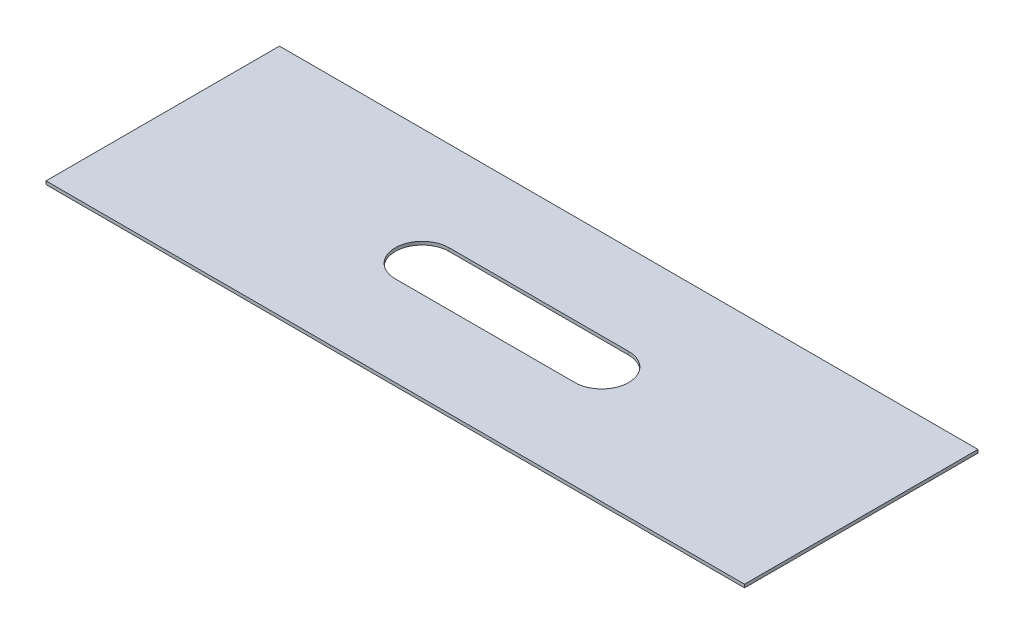
from build123d import *

# Parameters (mm, degrees)
SKETCH1_W           = 98.806
SKETCH1_H           = 33.02
BOSS_EXTRUDE1_DEPTH = 0.4572
CUT_EXTRUDE1_DEPTH  = 1.4572


with BuildPart() as part:
    # Sketch1 → Boss-Extrude1 (new body)
    with BuildSketch(Plane(origin=(0, 0, 0), x_dir=(1, 0, 0), z_dir=(0, 1, 0))):
        Rectangle(SKETCH1_W, SKETCH1_H)
    extrude(amount=BOSS_EXTRUDE1_DEPTH)

    # Sketch2 → Cut-Extrude1 (cut, through all)
    with BuildSketch(Plane(origin=(0, 0.4572, 0), x_dir=(1, 0, 0), z_dir=(0, 1, 0))):
        with BuildLine():
            Line((-12.7, 3.81), (12.7, 3.81))
            ThreePointArc((12.7, 3.81), (16.51, 0), (12.7, -3.81))
            Line((12.7, -3.81), (-12.7, -3.81))
            ThreePointArc((-12.7, -3.81), (-16.51, 0), (-12.7, 3.81))
        make_face()
    extrude(amount=-CUT_EXTRUDE1_DEPTH, mode=Mode.SUBTRACT)


solid = part.part
